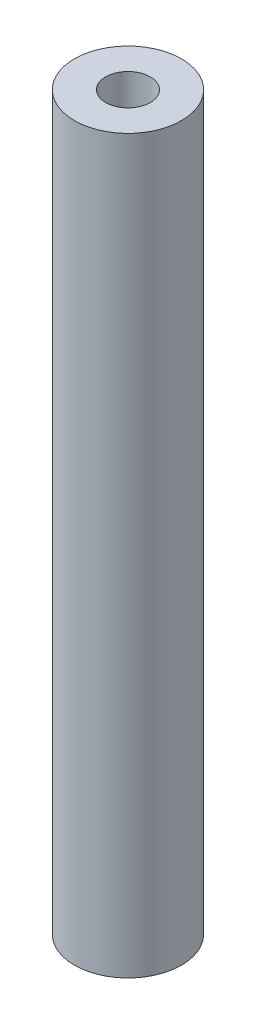
from build123d import *

# Parameters (mm, degrees)
SKETCH_1_R             = 3
EXTRUDE_1_DEPTH        = 41
HOLE_WIZARD_M3_1_D     = 2.5
HOLE_WIZARD_M3_1_DEPTH = 8.5
HOLE_WIZARD_M3_1_TIP   = 0.751075774
HOLE_WIZARD_M3_2_D     = 2.5
HOLE_WIZARD_M3_2_DEPTH = 8.5
HOLE_WIZARD_M3_2_TIP   = 0.751075774


with BuildPart() as part:
    # 草图1 → 凸台-拉伸1 (new body)
    with BuildSketch(Plane(origin=(0, 0, 0), x_dir=(1, 0, 0), z_dir=(0, 1, 0))):
        Circle(SKETCH_1_R)
    extrude(amount=EXTRUDE_1_DEPTH)

    # M3 螺纹孔1
    with Locations(Plane.ZX.offset(41)):
        with Locations((0, 0)):
            Hole(HOLE_WIZARD_M3_1_D / 2, depth=HOLE_WIZARD_M3_1_DEPTH)
            with Locations((0, 0, -(HOLE_WIZARD_M3_1_DEPTH + HOLE_WIZARD_M3_1_TIP / 2))):  # 118° drill point
                Cone(0, HOLE_WIZARD_M3_1_D / 2, HOLE_WIZARD_M3_1_TIP, mode=Mode.SUBTRACT)

    # M3 螺纹孔2
    with Locations(Plane(origin=(0, 0, 0), x_dir=(0, 0, -1), z_dir=(0, -1, 0))):
        with Locations((0, 0)):
            Hole(HOLE_WIZARD_M3_2_D / 2, depth=HOLE_WIZARD_M3_2_DEPTH)
            with Locations((0, 0, -(HOLE_WIZARD_M3_2_DEPTH + HOLE_WIZARD_M3_2_TIP / 2))):  # 118° drill point
                Cone(0, HOLE_WIZARD_M3_2_D / 2, HOLE_WIZARD_M3_2_TIP, mode=Mode.SUBTRACT)


solid = part.part
